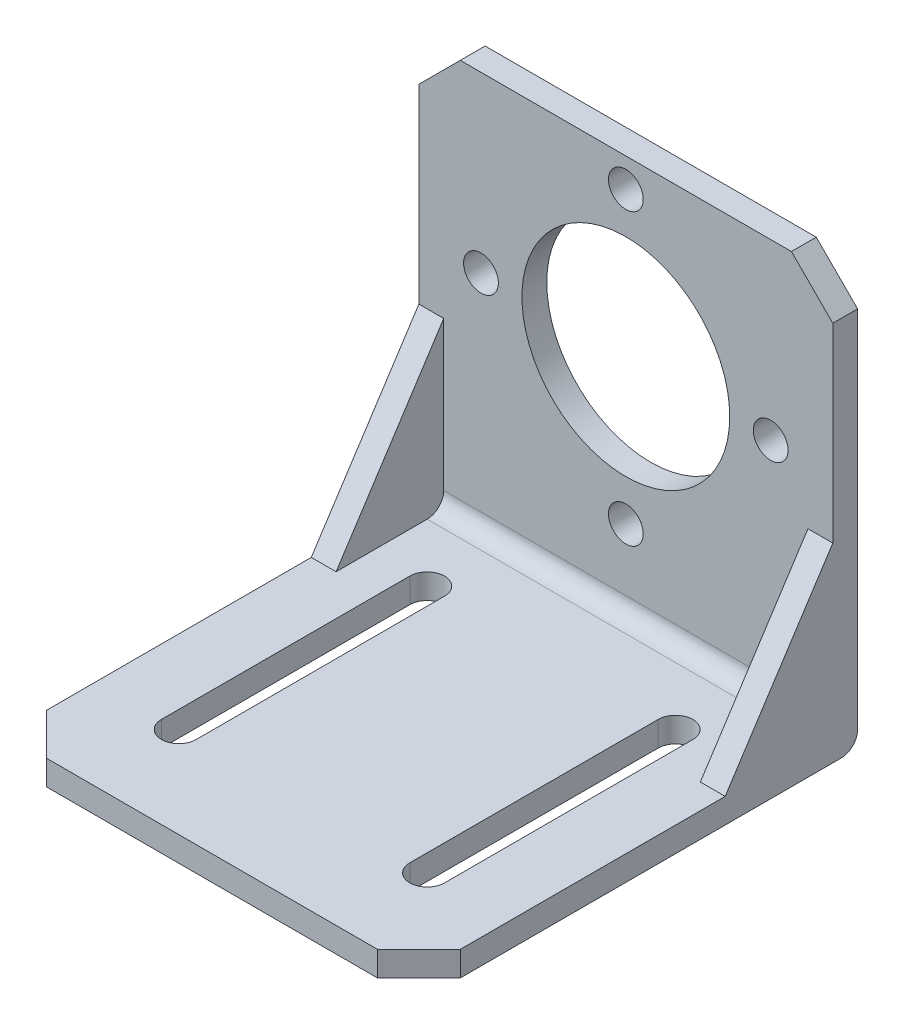
from build123d import *

# Parameters (mm, degrees)
SKETCH1_W           = 50
SKETCH1_H           = 51
BOSS_EXTRUDE1_DEPTH = 3
SKETCH2_W           = 50
SKETCH2_H           = 3
BOSS_EXTRUDE2_DEPTH = 50
FILLET1_R           = 2
CHAMFER1_SIZE       = 5
CUT_EXTRUDE1_DEPTH  = 50
SKETCH4_R           = 12.55
SKETCH4_R_2         = 2.1
CUT_EXTRUDE2_DEPTH  = 50
BOSS_EXTRUDE3_DEPTH = 3


with BuildPart() as part:
    # Sketch1 → Boss-Extrude1 (new body)
    with BuildSketch(Plane.XY):
        Rectangle(SKETCH1_W, SKETCH1_H)
    extrude(amount=BOSS_EXTRUDE1_DEPTH)

    # Sketch2 → Boss-Extrude2 (add)
    with BuildSketch(Plane.XY.offset(3)):
        with Locations((0, -24)):
            Rectangle(SKETCH2_W, SKETCH2_H)
    extrude(amount=BOSS_EXTRUDE2_DEPTH)

    # Fillet1
    fillet1_edges = [part.edges().sort_by_distance(p)[0] for p in [
        (0, -22.5, 3),
        (0, -25.5, 0),
    ]]
    fillet(fillet1_edges, radius=FILLET1_R)

    # Chamfer1
    chamfer1_edges = [part.edges().sort_by_distance(p)[0] for p in [
        (-25, -24, 53),
        (25, -24, 53),
        (-25, 25.5, 1.5),
        (25, 25.5, 1.5),
    ]]
    chamfer(chamfer1_edges, length=CHAMFER1_SIZE)

    # Sketch3 → Cut-Extrude1 (cut)
    with BuildSketch(Plane(origin=(0, -22.5, 0), x_dir=(1, 0, 0), z_dir=(0, 1, 0))):
        with BuildLine():
            Line((-17.1, -42), (-17.1, -12))
            ThreePointArc((-17.1, -12), (-15, -9.9), (-12.9, -12))
            Line((-12.9, -12), (-12.9, -42))
            ThreePointArc((-12.9, -42), (-15, -44.1), (-17.1, -42))
        make_face()
        with BuildLine():
            Line((12.9, -42), (12.9, -12))
            ThreePointArc((12.9, -12), (15, -9.9), (17.1, -12))
            Line((17.1, -12), (17.1, -42))
            ThreePointArc((17.1, -42), (15, -44.1), (12.9, -42))
        make_face()
    extrude(amount=-CUT_EXTRUDE1_DEPTH, mode=Mode.SUBTRACT)

    # Sketch4 → Cut-Extrude2 (cut)
    with BuildSketch(Plane.XY.offset(3)):
        with Locations((0, 4.5)):
            Circle(SKETCH4_R)
        with Locations((0, 22)):
            Circle(SKETCH4_R_2)
        with Locations((0, -13)):
            Circle(SKETCH4_R_2)
        with Locations((17.5, 4.5)):
            Circle(SKETCH4_R_2)
        with Locations((-17.5, 4.5)):
            Circle(SKETCH4_R_2)
    extrude(amount=-CUT_EXTRUDE2_DEPTH, mode=Mode.SUBTRACT)

    # Sketch5 → Boss-Extrude3 (add)
    with BuildSketch(Plane.ZY.offset(25)):
        with BuildLine():
            Line((3, -2.5), (16, -22.5))
            Line((16, -22.5), (5, -22.5))
            ThreePointArc((5, -22.5), (3.585786438, -21.914213562), (3, -20.5))
            Line((3, -20.5), (3, -2.5))
        make_face()
    boss_extrude3 = extrude(amount=-BOSS_EXTRUDE3_DEPTH)

    # Mirror1: Boss-Extrude3 across plane
    add(boss_extrude3.mirror(Plane(origin=(0, 0, 0), x_dir=(0, 0, 1), z_dir=(1, 0, 0))))


solid = part.part
